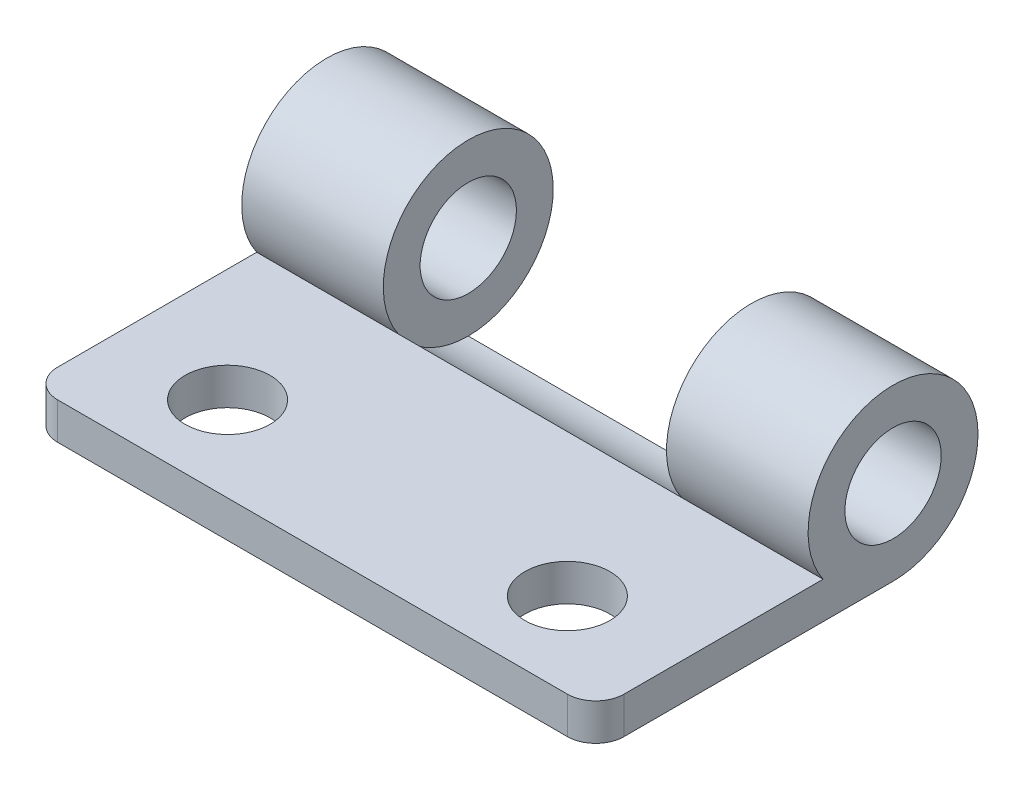
from build123d import *

# Parameters (mm, degrees)
SKETCH_1_W          = 10.5
SKETCH_1_H          = 1.3
EXTRUDE_2_DEPTH     = 20
SKETCH_2_R          = 3
SKETCH_2_R_2        = 1.7
EXTRUDE_3_DEPTH     = 5
SKETCH_3_R          = 3
CUT_EXTRUDE_1_DEPTH = 10
SKETCH_4_R          = 1.5
CUT_EXTRUDE_2_DEPTH = 10
FILLET_1_R          = 1


with BuildPart() as part:
    # 草图1 → 凸台-拉伸2 (new body)
    with BuildSketch(Plane(origin=(0, 0, 0), x_dir=(0, 0, -1), z_dir=(1, 0, 0))):
        with Locations((5.25, 0.65)):
            Rectangle(SKETCH_1_W, SKETCH_1_H)
    extrude(amount=EXTRUDE_2_DEPTH)

    # 草图2 → 凸台-拉伸3 (add)
    with BuildSketch(Plane(origin=(20, 0, 0), x_dir=(0, 0, -1), z_dir=(1, 0, 0))):
        with Locations((10.5, 3)):
            Circle(SKETCH_2_R)
        with Locations((10.5, 3)):
            Circle(SKETCH_2_R_2, mode=Mode.SUBTRACT)
    extrude_3 = extrude(amount=-EXTRUDE_3_DEPTH)

    # 草图3 → 切除-拉伸1 (cut)
    with BuildSketch(Plane.ZY.offset(-15)):
        with Locations((-10.5, 3)):
            Circle(SKETCH_3_R)
    extrude(amount=CUT_EXTRUDE_1_DEPTH, mode=Mode.SUBTRACT)

    # 镜向1: 凸台-拉伸3 across plane
    add(extrude_3.mirror(Plane.ZY.offset(-10)))

    # 草图4 → 切除-拉伸2 (cut)
    with BuildSketch(Plane(origin=(0, 1.3, 0), x_dir=(1, 0, 0), z_dir=(0, 1, 0))):
        with Locations((4, 3)):
            Circle(SKETCH_4_R)
    cut_extrude_2 = extrude(amount=-CUT_EXTRUDE_2_DEPTH, mode=Mode.SUBTRACT)

    # 镜向2: 切除-拉伸2 across plane
    add(cut_extrude_2.mirror(Plane.ZY.offset(-10)), mode=Mode.SUBTRACT)

    # 圆角1
    fillet_1_edges = [part.edges().sort_by_distance(p)[0] for p in [
        (20, 0.65, 0),
        (0, 0.65, 0),
    ]]
    fillet(fillet_1_edges, radius=FILLET_1_R)


solid = part.part
